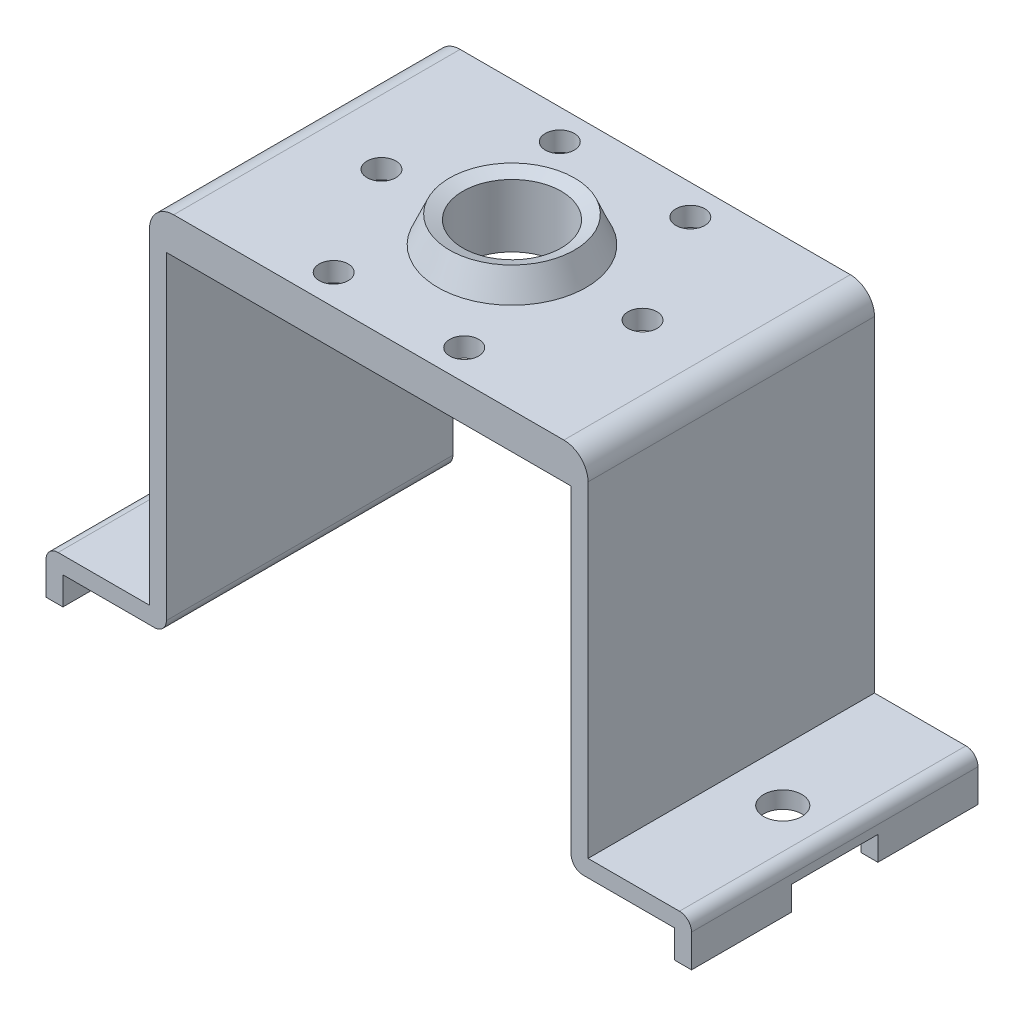
from build123d import *

# Parameters (mm, degrees)
SKETCH1_R                       = 7.7978
SKETCH1_R_2                     = 6.57225
SKETCH1_R_3                     = 5.17525
BOSS_EXTRUDE1_DEPTH             = 2.032
BOSS_EXTRUDE2_REACH             = 17.062
BOSS_EXTRUDE2_DIRECTION_2_REACH = 17.062
SKETCH4_W                       = 3.302
SKETCH4_H                       = 2.032
BOSS_EXTRUDE3_DEPTH             = 30.1244
FILLET1_R                       = 2.54
FILLET2_R                       = 2.54
SKETCH5_W                       = 9.0678
SKETCH5_H                       = 2.54
CUT_EXTRUDE1_DEPTH              = 116.84
SKETCH6_R                       = 2.01295
CUT_EXTRUDE2_DEPTH              = 5.7117
SKETCH7_R                       = 1.524
CUT_EXTRUDE3_DEPTH              = 42.5417
SKETCH9_W                       = 42.5577
SKETCH9_H                       = 30.1244
SKETCH9_W_2                     = 39.0017
SKETCH9_H_2                     = 26.5684
BOSS_EXTRUDE4_DEPTH             = 1.778


with BuildPart() as part:
    # Sketch1 → Boss-Extrude1 (new body)
    with BuildSketch(Plane(origin=(0, 0, 0), x_dir=(1, 0, 0), z_dir=(0, 1, 0))):
        with BuildLine():
            ThreePointArc((-23.05685, 9.9822), (-21.568952448, 13.574302448), (-17.97685, 15.0622))
            Line((-17.97685, 15.0622), (17.97685, 15.0622))
            ThreePointArc((17.97685, 15.0622), (21.568952448, 13.574302448), (23.05685, 9.9822))
            Line((23.05685, 9.9822), (23.05685, -9.9822))
            ThreePointArc((23.05685, -9.9822), (21.568952448, -13.574302448), (17.97685, -15.0622))
            Line((17.97685, -15.0622), (-17.97685, -15.0622))
            ThreePointArc((-17.97685, -15.0622), (-21.568952448, -13.574302448), (-23.05685, -9.9822))
            Line((-23.05685, -9.9822), (-23.05685, 9.9822))
        make_face()
        Circle(SKETCH1_R, mode=Mode.SUBTRACT)
        Circle(SKETCH1_R)
        Circle(SKETCH1_R_2, mode=Mode.SUBTRACT)
        Circle(SKETCH1_R_2)
        Circle(SKETCH1_R_3, mode=Mode.SUBTRACT)
    extrude(amount=-BOSS_EXTRUDE1_DEPTH)

    # Sketch2 → Revolve1 (revolve)
    with BuildSketch(Plane(origin=(0, 0, 0), x_dir=(0, 0, -1), z_dir=(1, 0, 0))):
        Polygon((-5.17525, 2.286), (-6.57225, 2.794), (-7.7978, 0), (-5.17525, 0), align=None)
    revolve1 = revolve(axis=Axis((0, 0, 0), (0, 1, 0)))

    # Boss-Extrude2: up to this face of the body (flat: up to its plane)
    boss_extrude2_end = Plane(part.part.faces().sort_by_distance((0, -1.016, 15.0622))[0])
    # Sketch3 → Boss-Extrude2 (add, up to the picked face)
    with BuildSketch(Plane.XY, mode=Mode.PRIVATE) as boss_extrude2_sk1:
        with BuildLine():
            ThreePointArc((-23.05685, -1.27), (-22.684875612, -0.371974388), (-21.78685, 0))
            Line((-21.78685, 0), (-21.27885, 0))
            Line((-21.27885, 0), (-21.27885, -37.338))
            ThreePointArc((-21.27885, -37.338), (-21.650824388, -38.236025612), (-22.54885, -38.608))
            Line((-22.54885, -38.608), (-23.05685, -38.608))
            Line((-23.05685, -38.608), (-32.16275, -38.608))
            Line((-32.16275, -38.608), (-32.16275, -41.5417))
            Line((-32.16275, -41.5417), (-33.94075, -41.5417))
            Line((-33.94075, -41.5417), (-33.94075, -38.1))
            ThreePointArc((-33.94075, -38.1), (-33.568775612, -37.201974388), (-32.67075, -36.83))
            Line((-32.67075, -36.83), (-32.16275, -36.83))
            Line((-32.16275, -36.83), (-23.05685, -36.83))
            Line((-23.05685, -36.83), (-23.05685, -1.27))
        make_face()
    boss_extrude2_tool1 = split(extrude(boss_extrude2_sk1.sketch, amount=BOSS_EXTRUDE2_REACH, mode=Mode.PRIVATE), bisect_by=boss_extrude2_end, keep=Keep.BOTH, mode=Mode.PRIVATE)
    add(boss_extrude2_tool1.solids().sort_by_distance((-32.41675, -37.264285, 0))[0])
    # Sketch3 → Boss-Extrude2 (add, up to the picked face)
    with BuildSketch(Plane.XY, mode=Mode.PRIVATE) as boss_extrude2_sk2:
        with BuildLine():
            Line((21.27885, 0), (21.27885, -37.338))
            ThreePointArc((21.27885, -37.338), (21.650824388, -38.236025612), (22.54885, -38.608))
            Line((22.54885, -38.608), (23.05685, -38.608))
            Line((23.05685, -38.608), (32.16275, -38.608))
            Line((32.16275, -38.608), (32.16275, -41.5417))
            Line((32.16275, -41.5417), (33.94075, -41.5417))
            Line((33.94075, -41.5417), (33.94075, -38.1))
            ThreePointArc((33.94075, -38.1), (33.568775612, -37.201974388), (32.67075, -36.83))
            Line((32.67075, -36.83), (32.16275, -36.83))
            Line((32.16275, -36.83), (23.05685, -36.83))
            Line((23.05685, -36.83), (23.05685, -1.27))
            ThreePointArc((23.05685, -1.27), (22.684875612, -0.371974388), (21.78685, 0))
            Line((21.78685, 0), (21.27885, 0))
        make_face()
    boss_extrude2_tool2 = split(extrude(boss_extrude2_sk2.sketch, amount=BOSS_EXTRUDE2_REACH, mode=Mode.PRIVATE), bisect_by=boss_extrude2_end, keep=Keep.BOTH, mode=Mode.PRIVATE)
    add(boss_extrude2_tool2.solids().sort_by_distance((27.6098, -38.173715, 0))[0])

    # Boss-Extrude2 direction 2: up to this face of the body (flat: up to its plane)
    boss_extrude2_direction_2_end = Plane(part.part.faces().sort_by_distance((0, -1.016, -15.0622))[0])
    # Sketch3 → Boss-Extrude2 direction 2 (add, up to the picked face)
    with BuildSketch(Plane.XY, mode=Mode.PRIVATE) as boss_extrude2_direction_2_sk1:
        with BuildLine():
            ThreePointArc((-23.05685, -1.27), (-22.684875612, -0.371974388), (-21.78685, 0))
            Line((-21.78685, 0), (-21.27885, 0))
            Line((-21.27885, 0), (-21.27885, -37.338))
            ThreePointArc((-21.27885, -37.338), (-21.650824388, -38.236025612), (-22.54885, -38.608))
            Line((-22.54885, -38.608), (-23.05685, -38.608))
            Line((-23.05685, -38.608), (-32.16275, -38.608))
            Line((-32.16275, -38.608), (-32.16275, -41.5417))
            Line((-32.16275, -41.5417), (-33.94075, -41.5417))
            Line((-33.94075, -41.5417), (-33.94075, -38.1))
            ThreePointArc((-33.94075, -38.1), (-33.568775612, -37.201974388), (-32.67075, -36.83))
            Line((-32.67075, -36.83), (-32.16275, -36.83))
            Line((-32.16275, -36.83), (-23.05685, -36.83))
            Line((-23.05685, -36.83), (-23.05685, -1.27))
        make_face()
    boss_extrude2_direction_2_tool1 = split(extrude(boss_extrude2_direction_2_sk1.sketch, amount=-BOSS_EXTRUDE2_DIRECTION_2_REACH, mode=Mode.PRIVATE), bisect_by=boss_extrude2_direction_2_end, keep=Keep.BOTH, mode=Mode.PRIVATE)
    add(boss_extrude2_direction_2_tool1.solids().sort_by_distance((-32.41675, -37.264285, 0))[0])
    # Sketch3 → Boss-Extrude2 direction 2 (add, up to the picked face)
    with BuildSketch(Plane.XY, mode=Mode.PRIVATE) as boss_extrude2_direction_2_sk2:
        with BuildLine():
            Line((21.27885, 0), (21.27885, -37.338))
            ThreePointArc((21.27885, -37.338), (21.650824388, -38.236025612), (22.54885, -38.608))
            Line((22.54885, -38.608), (23.05685, -38.608))
            Line((23.05685, -38.608), (32.16275, -38.608))
            Line((32.16275, -38.608), (32.16275, -41.5417))
            Line((32.16275, -41.5417), (33.94075, -41.5417))
            Line((33.94075, -41.5417), (33.94075, -38.1))
            ThreePointArc((33.94075, -38.1), (33.568775612, -37.201974388), (32.67075, -36.83))
            Line((32.67075, -36.83), (32.16275, -36.83))
            Line((32.16275, -36.83), (23.05685, -36.83))
            Line((23.05685, -36.83), (23.05685, -1.27))
            ThreePointArc((23.05685, -1.27), (22.684875612, -0.371974388), (21.78685, 0))
            Line((21.78685, 0), (21.27885, 0))
        make_face()
    boss_extrude2_direction_2_tool2 = split(extrude(boss_extrude2_direction_2_sk2.sketch, amount=-BOSS_EXTRUDE2_DIRECTION_2_REACH, mode=Mode.PRIVATE), bisect_by=boss_extrude2_direction_2_end, keep=Keep.BOTH, mode=Mode.PRIVATE)
    add(boss_extrude2_direction_2_tool2.solids().sort_by_distance((27.6098, -38.173715, 0))[0])

    # Sketch4 → Boss-Extrude3 (add)
    with BuildSketch(Plane.XY.offset(15.0622)):
        with BuildLine():
            ThreePointArc((-23.05685, -1.27), (-22.684875612, -0.371974388), (-21.78685, 0))
            Line((-21.78685, 0), (-23.05685, 0))
            Line((-23.05685, 0), (-23.05685, -1.27))
        make_face()
        with BuildLine():
            Line((-21.27885, -2.032), (-21.27885, 0))
            Line((-21.27885, 0), (-21.78685, 0))
            ThreePointArc((-21.78685, 0), (-22.684875612, -0.371974388), (-23.05685, -1.27))
            Line((-23.05685, -1.27), (-23.05685, -2.032))
            Line((-23.05685, -2.032), (-21.27885, -2.032))
        make_face()
        with Locations((-19.62785, -1.016)):
            Rectangle(SKETCH4_W, SKETCH4_H)
        Polygon((23.05685, 0), (21.27885, 0), (17.97685, 0), (17.97685, -2.032), (21.27885, -2.032), (23.05685, -2.032), align=None)
    extrude(amount=-BOSS_EXTRUDE3_DEPTH)

    # Fillet1
    fillet1_edges = [part.edges().sort_by_distance(p)[0] for p in [
        (23.05685, 0, 0),
    ]]
    fillet(fillet1_edges, radius=FILLET1_R)

    # Fillet2
    fillet2_edges = [part.edges().sort_by_distance(p)[0] for p in [
        (-23.05685, 0, 0),
    ]]
    fillet(fillet2_edges, radius=FILLET2_R)

    # Sketch5 → Cut-Extrude1 (cut)
    with BuildSketch(Plane.ZY.offset(33.94075)):
        with Locations((0, -40.2717)):
            Rectangle(SKETCH5_W, SKETCH5_H)
    extrude(amount=-CUT_EXTRUDE1_DEPTH, mode=Mode.SUBTRACT)

    # Sketch6 → Cut-Extrude2 (cut, through all)
    with BuildSketch(Plane(origin=(0, -36.83, 0), x_dir=(1, 0, 0), z_dir=(0, 1, 0))):
        with Locations((-28.4734, 0)):
            Circle(SKETCH6_R)
        with Locations((28.4734, 0)):
            Circle(SKETCH6_R)
    extrude(amount=-CUT_EXTRUDE2_DEPTH, mode=Mode.SUBTRACT)

    # Sketch7 → Cut-Extrude3 (cut, through all)
    with BuildSketch(Plane(origin=(0, 0, 0), x_dir=(1, 0, 0), z_dir=(0, 1, 0))):
        with Locations((13.725830849, 0)):
            Circle(SKETCH7_R)
        with Locations((-13.725830849, 0)):
            Circle(SKETCH7_R)
        with Locations((-6.862915424, -11.886918203)):
            Circle(SKETCH7_R)
        with Locations((6.862915424, 11.886918203)):
            Circle(SKETCH7_R)
        with Locations((-6.862915424, 11.886918203)):
            Circle(SKETCH7_R)
        with Locations((6.862915424, -11.886918203)):
            Circle(SKETCH7_R)
    extrude(amount=-CUT_EXTRUDE3_DEPTH, mode=Mode.SUBTRACT)

    # Mirror4: Revolve1 across plane
    add(revolve1.mirror(Plane.ZX.offset(-1.016)))

    # Sketch9 → Boss-Extrude4 (add)
    with BuildSketch(Plane.XZ.offset(2.032)):
        Rectangle(SKETCH9_W, SKETCH9_H)
        Rectangle(SKETCH9_W_2, SKETCH9_H_2, mode=Mode.SUBTRACT)
    extrude(amount=BOSS_EXTRUDE4_DEPTH)


solid = part.part
